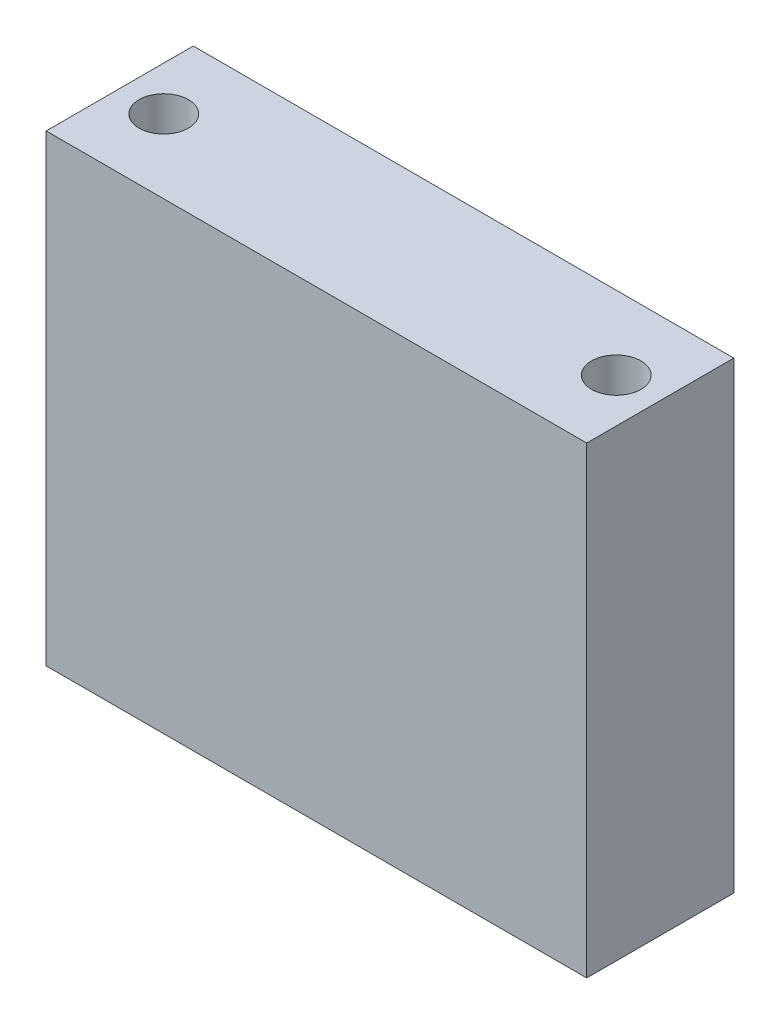
from build123d import *

# Parameters (mm, degrees)
SKETCH1_W            = 35
SKETCH1_H            = 9.525
BOSS_EXTRUDE1_DEPTH  = 30
M3_CLEARANCE_HOLE1_D = 3.2


with BuildPart() as part:
    # Sketch1 → Boss-Extrude1 (new body)
    with BuildSketch(Plane(origin=(0, 0, 0), x_dir=(1, 0, 0), z_dir=(0, 1, 0))):
        Rectangle(SKETCH1_W, SKETCH1_H)
    extrude(amount=BOSS_EXTRUDE1_DEPTH)

    # M3 Clearance Hole1 (through all)
    with Locations(Plane(origin=(0, 30, 0), x_dir=(1, 0, 0), z_dir=(0, 1, 0))):
        with Locations((14.65, 0), (-14.65, 0)):
            Hole(M3_CLEARANCE_HOLE1_D / 2)


solid = part.part
